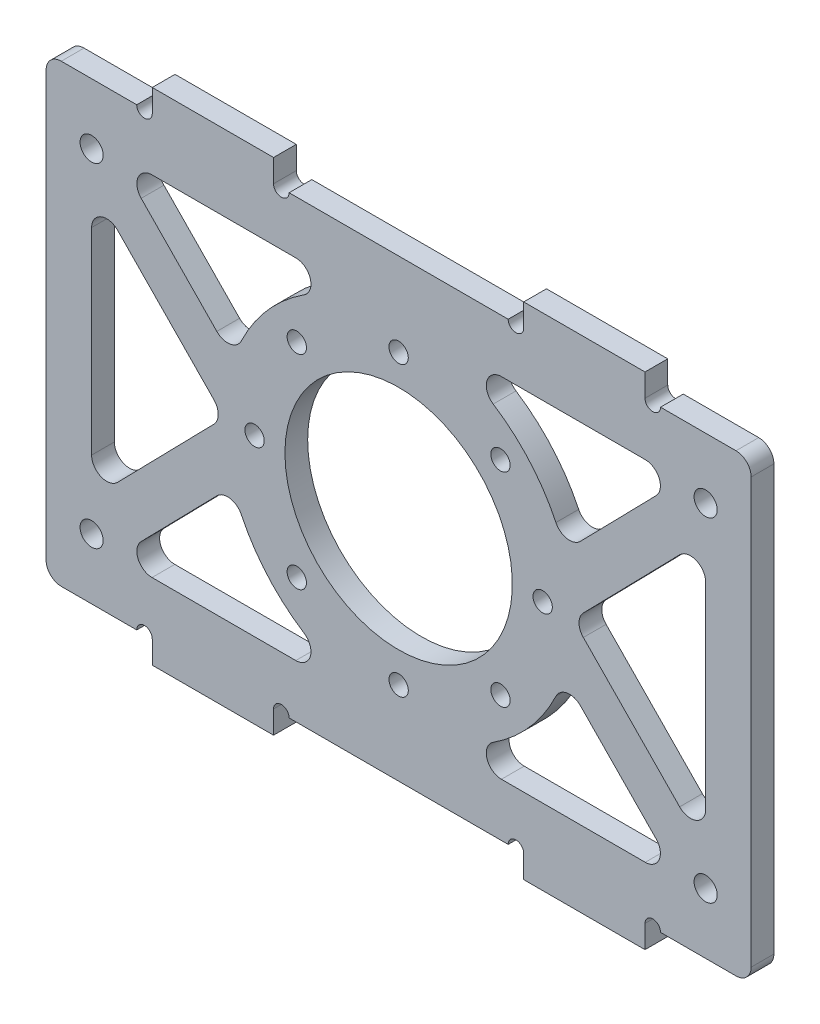
from build123d import *

# Parameters (mm, degrees)
SKETCH_1_W               = 93
SKETCH_1_H               = 60
EXTRUDE_1_DEPTH          = 1.5
SKETCH_2_R               = 15
CUT_EXTRUDE_1_DEPTH      = 12
SKETCH_4_R               = 1.525
CUT_EXTRUDE_3_DEPTH      = 15
SKETCH_5_R               = 1.275
CUT_EXTRUDE_4_DEPTH      = 15
CUT_EXTRUDE_7_DEPTH      = 10
FILLET_3_R               = 2
FILLET_3_OF_MIRROR_3_R   = 2
FILLET_4_R               = 2
SKETCH_10_W              = 16
SKETCH_10_H              = 6
EXTRUDE_2_DEPTH          = 3
MIRROR_5_COPY_1_SKETCH_W = 16
MIRROR_5_COPY_1_SKETCH_H = 6
MIRROR_5_COPY_1_DEPTH    = 3
SKETCH_11_R              = 1.025
CUT_EXTRUDE_8_DEPTH      = 3


with BuildPart() as part:
    # 草图1 → 凸台-拉伸1 (new body, symmetric)
    with BuildSketch(Plane.XY):
        Rectangle(SKETCH_1_W, SKETCH_1_H)
    extrude(amount=EXTRUDE_1_DEPTH, both=True)

    # 草图2 → 切除-拉伸1 (cut, symmetric)
    with BuildSketch(Plane.XY.offset(1.5)):
        Circle(SKETCH_2_R)
    extrude(amount=CUT_EXTRUDE_1_DEPTH, both=True, mode=Mode.SUBTRACT)

    # 草图4 → 切除-拉伸3 (cut, symmetric)
    with BuildSketch(Plane.XY.offset(1.5)):
        with Locations((40.5, -22)):
            Circle(SKETCH_4_R)
        with Locations((40.5, 22)):
            Circle(SKETCH_4_R)
        with Locations((-40.5, -22)):
            Circle(SKETCH_4_R)
        with Locations((-40.5, 22)):
            Circle(SKETCH_4_R)
    extrude(amount=CUT_EXTRUDE_3_DEPTH, both=True, mode=Mode.SUBTRACT)

    # 草图5 → 切除-拉伸4 (cut, symmetric)
    with BuildSketch(Plane.XY.offset(1.5)):
        with Locations((0, 19)):
            Circle(SKETCH_5_R)
        with Locations((13.435028843, 13.435028843)):
            Circle(SKETCH_5_R)
        with Locations((19, 0)):
            Circle(SKETCH_5_R)
        with Locations((13.435028843, -13.435028843)):
            Circle(SKETCH_5_R)
        with Locations((0, -19)):
            Circle(SKETCH_5_R)
        with Locations((-13.435028843, -13.435028843)):
            Circle(SKETCH_5_R)
        with Locations((-19, 0)):
            Circle(SKETCH_5_R)
        with Locations((-13.435028843, 13.435028843)):
            Circle(SKETCH_5_R)
    extrude(amount=CUT_EXTRUDE_4_DEPTH, both=True, mode=Mode.SUBTRACT)

    # 草图9 → 切除-拉伸7 (cut)
    with BuildSketch(Plane.XY.offset(1.5)):
        Polygon((40.5, 17.906976744), (23, 0), (40.5, -17.906976744), align=None)
        with BuildLine():
            Line((37.282566796, 23), (21.843403436, 7.201786329))
            ThreePointArc((21.843403436, 7.201786329), (13.478852222, 18.636537843), (0, 23))
            Line((0, 23), (37.282566796, 23))
        make_face()
        with BuildLine():
            Line((37.282566796, -23), (0, -23))
            ThreePointArc((0, -23), (13.478852222, -18.636537843), (21.843403436, -7.201786329))
            Line((21.843403436, -7.201786329), (37.282566796, -23))
        make_face()
    cut_extrude_7 = extrude(amount=-CUT_EXTRUDE_7_DEPTH, mode=Mode.SUBTRACT)

    # 圆角3
    fillet_3_edges = [part.edges().sort_by_distance(p)[0] for p in [
        (0, -23, 0),
        (21.843403436, -7.201786329, 0),
        (37.282566796, -23, 0),
        (0, 23, 0),
        (37.282566796, 23, 0),
        (21.843403436, 7.201786329, 0),
        (40.5, 17.906976744, 0),
        (40.5, -17.906976744, 0),
        (23, 0, 0),
    ]]
    fillet(fillet_3_edges, radius=FILLET_3_R)

    # 镜向3: 切除-拉伸7 across plane
    add(cut_extrude_7.mirror(Plane(origin=(0, 0, 0), x_dir=(0, 0, 1), z_dir=(1, 0, 0))), mode=Mode.SUBTRACT)

    # 圆角3 of 镜向3
    fillet_3_of_mirror_3_edges = [part.edges().sort_by_distance(p)[0] for p in [
        (0, -23, 0),
        (-21.843403436, -7.201786329, 0),
        (-37.282566796, -23, 0),
        (0, 23, 0),
        (-37.282566796, 23, 0),
        (-21.843403436, 7.201786329, 0),
        (-40.5, 17.906976744, 0),
        (-40.5, -17.906976744, 0),
        (-23, 0, 0),
    ]]
    fillet(fillet_3_of_mirror_3_edges, radius=FILLET_3_OF_MIRROR_3_R)

    # 圆角4
    fillet_4_edges = [part.edges().sort_by_distance(p)[0] for p in [
        (46.5, -30, 0),
        (-46.5, -30, 0),
        (-46.5, 30, 0),
        (46.5, 30, 0),
    ]]
    fillet(fillet_4_edges, radius=FILLET_4_R)

    # 草图10 → 凸台-拉伸2 (add)
    with BuildSketch(Plane(origin=(0, 0, -1.5), x_dir=(-1, 0, 0), z_dir=(0, 0, -1))):
        with Locations((-24.5, 30)):
            Rectangle(SKETCH_10_W, SKETCH_10_H)
    extrude_2 = extrude(amount=-EXTRUDE_2_DEPTH)

    # 镜向4: 凸台-拉伸2 across plane
    add(extrude_2.mirror(Plane(origin=(0, 0, 0), x_dir=(0, 0, 1), z_dir=(1, 0, 0))))

    # 镜向5: 凸台-拉伸2 across plane
    add(extrude_2.mirror(Plane.ZX))

    # 镜向5 copy 1 sketch → 镜向5 copy 1 (add)
    with BuildSketch(Plane(origin=(0, 0, -1.5), x_dir=(1, 0, 0), z_dir=(0, 0, -1))):
        with Locations((-24.5, 30)):
            Rectangle(MIRROR_5_COPY_1_SKETCH_W, MIRROR_5_COPY_1_SKETCH_H)
    extrude(amount=-MIRROR_5_COPY_1_DEPTH)

    # 草图11 → 切除-拉伸8 (cut)
    with BuildSketch(Plane.XY.offset(1.5)):
        with Locations((33.525, 30)):
            Circle(SKETCH_11_R)
        with Locations((15.475, 30)):
            Circle(SKETCH_11_R)
        with Locations((-15.475, 30)):
            Circle(SKETCH_11_R)
        with Locations((-33.525, 30)):
            Circle(SKETCH_11_R)
        with Locations((-33.525, -30)):
            Circle(SKETCH_11_R)
        with Locations((-15.475, -30)):
            Circle(SKETCH_11_R)
        with Locations((15.475, -30)):
            Circle(SKETCH_11_R)
        with Locations((33.525, -30)):
            Circle(SKETCH_11_R)
    extrude(amount=-CUT_EXTRUDE_8_DEPTH, mode=Mode.SUBTRACT)


solid = part.part
